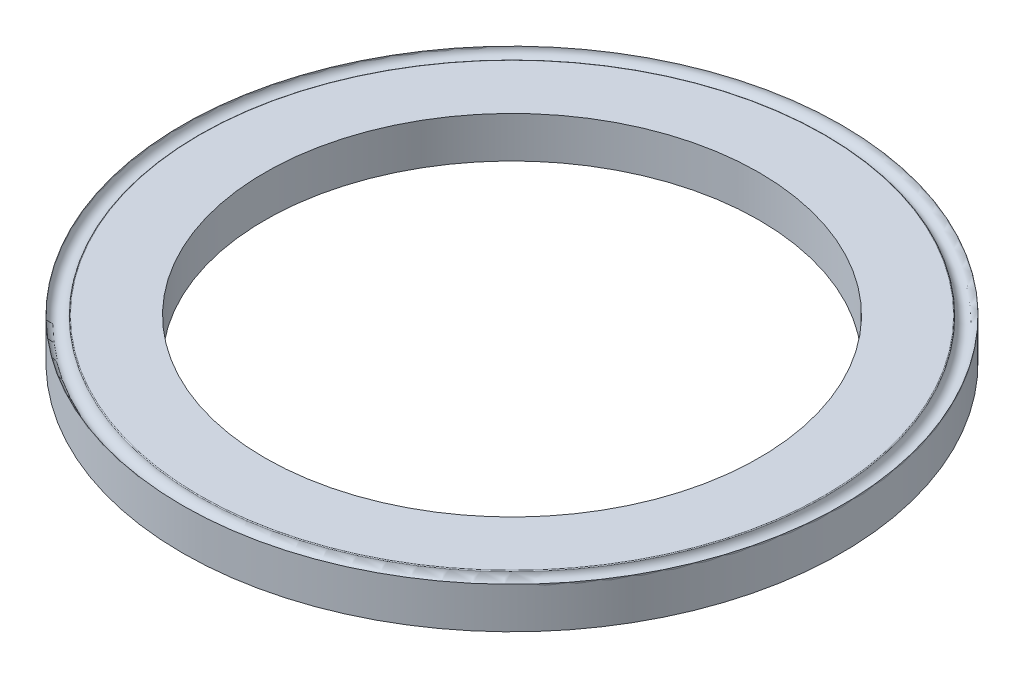
from build123d import *

# Parameters (mm, degrees)
DIAPROFILES_R    = 4
DIAPROFILES_R_2  = 3
DIAPROFILE_DEPTH = 0.25


with BuildPart() as part:
    # DiaProfileS → DiaProfile (new body, symmetric)
    with BuildSketch(Plane(origin=(0, 0, 0), x_dir=(1, 0, 0), z_dir=(0, 1, 0))):
        Circle(DIAPROFILES_R)
        Circle(DIAPROFILES_R_2, mode=Mode.SUBTRACT)
    extrude(amount=DIAPROFILE_DEPTH, both=True)

    # CrimpS → Crimp (revolve, cut)
    with BuildSketch(Plane.XY):
        with BuildLine():
            Line((-4, 0.25), (-3.790455488, 0.25))
            ThreePointArc((-3.790455488, 0.25), (-3.797197487, 0.247385489), (-3.80041408, 0.240909091))
            ThreePointArc((-3.80041408, 0.240909091), (-3.904550167, 0.150103574), (-4, 0.25))
        make_face()
    revolve(axis=Axis((0, 0.25, 0), (0, -1, 0)), mode=Mode.SUBTRACT)


solid = part.part
